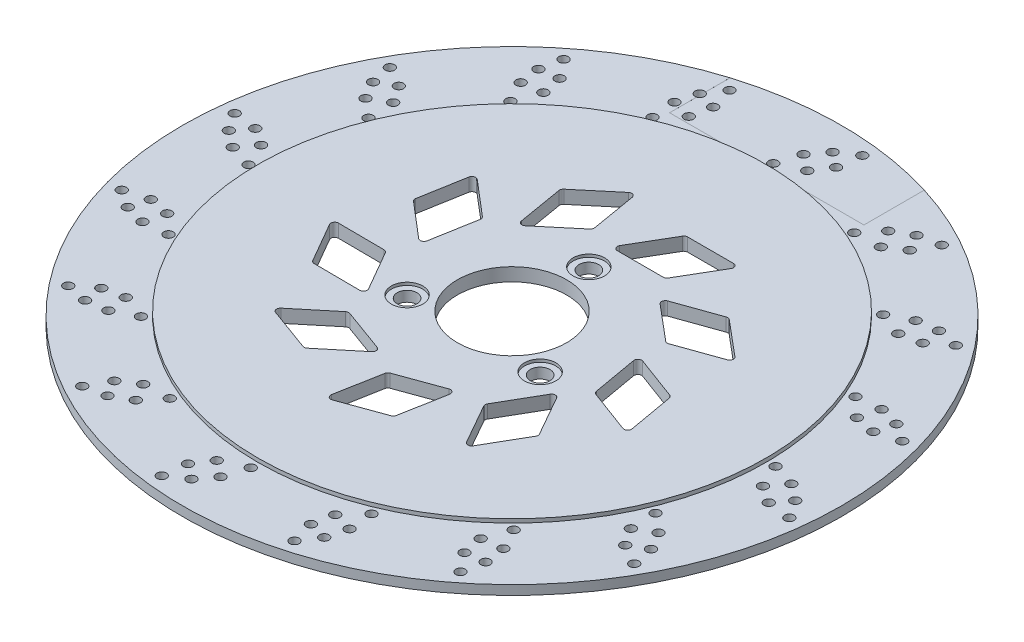
from build123d import *

# Parameters (mm, degrees)
SKETCH1_R           = 135
SKETCH1_R_2         = 29
BOSS_EXTRUDE1_DEPTH = 7
SKETCH1_3_R         = 175
SKETCH1_3_R_2       = 135
BOSS_EXTRUDE2_DEPTH = 5
SKETCH7_R           = 5.2
CUT_EXTRUDE9_DEPTH  = 248.586348574
SKETCH11_R          = 8.35
CUT_EXTRUDE10_DEPTH = 1.5
CIRPATTERN1_COUNT   = 3
CIRPATTERN2_COUNT   = 3
CUT_EXTRUDE11_DEPTH = 248.586348574
SKETCH14_R          = 2.5
CUT_EXTRUDE12_DEPTH = 248.53787589
CIRPATTERN3_COUNT   = 16
SKETCH15_R          = 175
SKETCH15_R_2        = 135
CUT_EXTRUDE13_DEPTH = 0.01
SKETCH16_W          = 103.216038505
SKETCH16_H          = 40.53333701
CUT_EXTRUDE14_DEPTH = 0.01
SKETCH17_W          = 102.14000893
SKETCH17_H          = 42.38101065
CUT_EXTRUDE15_DEPTH = 0.01


with BuildPart() as part:
    # Sketch1 → Boss-Extrude1 (new body)
    with BuildSketch(Plane(origin=(0, 0, 0), x_dir=(1, 0, 0), z_dir=(0, 1, 0))):
        Circle(SKETCH1_R)
        Circle(SKETCH1_R_2, mode=Mode.SUBTRACT)
    extrude(amount=BOSS_EXTRUDE1_DEPTH)

    # Sketch1_3 → Boss-Extrude2 (add)
    with BuildSketch(Plane(origin=(0, 0, 0), x_dir=(1, 0, 0), z_dir=(0, 1, 0))):
        Circle(SKETCH1_3_R)
        Circle(SKETCH1_3_R_2, mode=Mode.SUBTRACT)
    extrude(amount=BOSS_EXTRUDE2_DEPTH)

    # Sketch7 → Cut-Extrude9 (cut, through all)
    with BuildSketch(Plane(origin=(0, 7, 0), x_dir=(1, 0, 0), z_dir=(0, 1, 0))):
        with Locations((0, 40.8)):
            Circle(SKETCH7_R)
    cut_extrude9 = extrude(amount=-CUT_EXTRUDE9_DEPTH, mode=Mode.SUBTRACT)

    # Sketch11 → Cut-Extrude10 (cut)
    with BuildSketch(Plane(origin=(0, 7, 0), x_dir=(1, 0, 0), z_dir=(0, 1, 0))):
        with Locations((0, 40.8)):
            Circle(SKETCH11_R)
    cut_extrude10 = extrude(amount=-CUT_EXTRUDE10_DEPTH, mode=Mode.SUBTRACT)

    # CirPattern1: Cut-Extrude9 ×3 about axis
    cirpattern1_axis = Axis((0, 7, 0), (0, 1, 0))
    for i in range(1, CIRPATTERN1_COUNT):
        add(cut_extrude9.rotate(cirpattern1_axis, i * 360 / CIRPATTERN1_COUNT), mode=Mode.SUBTRACT)

    # CirPattern2: Cut-Extrude10 ×3 about axis
    cirpattern2_axis = Axis((0, 7, 0), (0, 1, 0))
    for i in range(1, CIRPATTERN2_COUNT):
        add(cut_extrude10.rotate(cirpattern2_axis, i * 360 / CIRPATTERN2_COUNT), mode=Mode.SUBTRACT)

    # Sketch13 → Cut-Extrude11 (cut, through all)
    with BuildSketch(Plane(origin=(0, 7, 0), x_dir=(1, 0, 0), z_dir=(0, 1, 0))):
        with BuildLine():
            Line((0.125749805, 55.8), (24.472230204, 55.8))
            ThreePointArc((24.472230204, 55.8), (25.466236439, 56.064502491), (26.197325549, 56.788048395))
            Line((26.197325549, 56.788048395), (38.516055508, 77.788048395))
            ThreePointArc((38.516055508, 77.788048395), (38.526457673, 79.794006235), (36.790960164, 80.8))
            Line((36.790960164, 80.8), (12.444479765, 80.8))
            ThreePointArc((12.444479765, 80.8), (11.45047353, 80.535497509), (10.71938442, 79.811951605))
            Line((10.71938442, 79.811951605), (-1.599345539, 58.811951605))
            ThreePointArc((-1.599345539, 58.811951605), (-1.609747704, 56.805993765), (0.125749805, 55.8))
        make_face()
        with BuildLine():
            Line((80.119731336, 38.247949908), (61.469245317, 53.897565848))
            ThreePointArc((61.469245317, 53.897565848), (60.537773441, 54.333880077), (59.512640348, 54.249546779))
            Line((59.512640348, 54.249546779), (36.577405913, 46.080940458))
            ThreePointArc((36.577405913, 46.080940458), (35.280032548, 44.550973984), (35.962860444, 42.664781755))
            Line((35.962860444, 42.664781755), (54.613346463, 27.015165815))
            ThreePointArc((54.613346463, 27.015165815), (55.544818339, 26.578851587), (56.569951431, 26.663184884))
            Line((56.569951431, 26.663184884), (79.505185866, 34.831791205))
            ThreePointArc((79.505185866, 34.831791205), (80.802559232, 36.361757679), (80.119731336, 38.247949908))
        make_face()
        with BuildLine():
            Line((85.959565155, -22.200008861), (81.731843201, 1.776593795))
            ThreePointArc((81.731843201, 1.776593795), (81.298751726, 2.709568466), (80.459245818, 3.303908262))
            Line((80.459245818, 3.303908262), (57.639157996, 11.788877302))
            ThreePointArc((57.639157996, 11.788877302), (55.661868846, 11.450790511), (54.972524367, 9.566970124))
            Line((54.972524367, 9.566970124), (59.200246321, -14.409632531))
            ThreePointArc((59.200246321, -14.409632531), (59.633337795, -15.342607202), (60.472843703, -15.936946998))
            Line((60.472843703, -15.936946998), (83.292931525, -24.421916038))
            ThreePointArc((83.292931525, -24.421916038), (85.270220675, -24.083829247), (85.959565155, -22.200008861))
        make_face()
        with BuildLine():
            Line((51.577938472, -72.259604595), (63.751178672, -51.174934076))
            ThreePointArc((63.751178672, -51.174934076), (64.019115913, -50.18184818), (63.758051334, -49.186933486))
            Line((63.758051334, -49.186933486), (51.730882834, -28.018600399))
            ThreePointArc((51.730882834, -28.018600399), (49.998873468, -27.006612941), (48.259908557, -28.006600989))
            Line((48.259908557, -28.006600989), (36.086668357, -49.091271507))
            ThreePointArc((36.086668357, -49.091271507), (35.818731116, -50.084357404), (36.079795695, -51.079272097))
            Line((36.079795695, -51.079272097), (48.106964195, -72.247605185))
            ThreePointArc((48.106964195, -72.247605185), (49.838973561, -73.259592643), (51.577938472, -72.259604595))
        make_face()
        with BuildLine():
            Line((-6.937603477, -88.507396099), (15.940604496, -80.180409384))
            ThreePointArc((15.940604496, -80.180409384), (16.78419964, -79.59188819), (17.223731408, -78.661930241))
            Line((17.223731408, -78.661930241), (21.617128039, -54.715131418))
            ThreePointArc((21.617128039, -54.715131418), (20.940824888, -52.826589888), (18.965920553, -52.474840078))
            Line((18.965920553, -52.474840078), (-3.91228742, -60.801826793))
            ThreePointArc((-3.91228742, -60.801826793), (-4.755882564, -61.390347987), (-5.195414332, -62.320305936))
            Line((-5.195414332, -62.320305936), (-9.588810962, -86.267104759))
            ThreePointArc((-9.588810962, -86.267104759), (-8.912507811, -88.155646288), (-6.937603477, -88.507396099))
        make_face()
        with BuildLine():
            Line((-62.206988287, -63.340861155), (-39.328780314, -71.667847871))
            ThreePointArc((-39.328780314, -71.667847871), (-38.30425481, -71.759266987), (-37.369788494, -71.329403442))
            Line((-37.369788494, -71.329403442), (-18.611545844, -55.809112192))
            ThreePointArc((-18.611545844, -55.809112192), (-17.915693019, -53.927686162), (-19.20245709, -52.388786137))
            Line((-19.20245709, -52.388786137), (-42.080665063, -44.061799422))
            ThreePointArc((-42.080665063, -44.061799422), (-43.105190567, -43.970380305), (-44.039656883, -44.40024385))
            Line((-44.039656883, -44.40024385), (-62.797899533, -59.9205351))
            ThreePointArc((-62.797899533, -59.9205351), (-63.493752358, -61.80196113), (-62.206988287, -63.340861155))
        make_face()
        with BuildLine():
            Line((-88.369056554, -8.535701158), (-76.195816355, -29.620371676))
            ThreePointArc((-76.195816355, -29.620371676), (-75.469747361, -30.348955082), (-74.477593672, -30.620323871))
            Line((-74.477593672, -30.620323871), (-50.131695213, -30.788656958))
            ThreePointArc((-50.131695213, -30.788656958), (-48.389283682, -29.794686577), (-48.38581628, -27.788704763))
            Line((-48.38581628, -27.788704763), (-60.55905648, -6.704034245))
            ThreePointArc((-60.55905648, -6.704034245), (-61.285125474, -5.975450839), (-62.277279162, -5.70408205))
            Line((-62.277279162, -5.70408205), (-86.623177622, -5.535748963))
            ThreePointArc((-86.623177622, -5.535748963), (-88.365589152, -6.529719344), (-88.369056554, -8.535701158))
        make_face()
        with BuildLine():
            Line((-73.182285778, 50.264140438), (-77.410007732, 26.287537783))
            ThreePointArc((-77.410007732, 26.287537783), (-77.322131, 25.262702361), (-76.736529675, 24.41707771))
            Line((-76.736529675, 24.41707771), (-58.19469187, 8.638885207))
            ThreePointArc((-58.19469187, 8.638885207), (-56.221015354, 8.280310152), (-54.928938915, 9.81475257))
            Line((-54.928938915, 9.81475257), (-50.701216961, 33.791355226))
            ThreePointArc((-50.701216961, 33.791355226), (-50.789093693, 34.816190648), (-51.374695018, 35.661815299))
            Line((-51.374695018, 35.661815299), (-69.916532823, 51.440007801))
            ThreePointArc((-69.916532823, 51.440007801), (-71.890209339, 51.798582857), (-73.182285778, 50.264140438))
        make_face()
        with BuildLine():
            Line((-23.752734786, 85.545564263), (-42.403220805, 69.895948324))
            ThreePointArc((-42.403220805, 69.895948324), (-42.994654834, 69.054392769), (-43.089615242, 68.030189428))
            Line((-43.089615242, 68.030189428), (-39.02777007, 44.024929137))
            ThreePointArc((-39.02777007, 44.024929137), (-37.746333745, 42.481589899), (-35.770225195, 42.826510261))
            Line((-35.770225195, 42.826510261), (-17.119739176, 58.4761262))
            ThreePointArc((-17.119739176, 58.4761262), (-16.528305147, 59.317681755), (-16.433344739, 60.341885096))
            Line((-16.433344739, 60.341885096), (-20.495189911, 84.347145387))
            ThreePointArc((-20.495189911, 84.347145387), (-21.776626235, 85.890484625), (-23.752734786, 85.545564263))
        make_face()
    extrude(amount=-CUT_EXTRUDE11_DEPTH, mode=Mode.SUBTRACT)

    # Sketch14 → Cut-Extrude12 (cut, through all)
    with BuildSketch(Plane(origin=(0, 5, 0), x_dir=(1, 0, 0), z_dir=(0, 1, 0))):
        with Locations((19.371769386, 166.652812155)):
            Circle(SKETCH14_R)
        with Locations((-0.614063154, 139.355520084)):
            Circle(SKETCH14_R)
        with Locations((9.923971718, 160.30436076)):
            Circle(SKETCH14_R)
        with Locations((3.241074211, 151.567148337)):
            Circle(SKETCH14_R)
        with Locations((17.867298021, 154.229530124)):
            Circle(SKETCH14_R)
        with Locations((11.764209377, 145.048000991)):
            Circle(SKETCH14_R)
    cut_extrude12 = extrude(amount=-CUT_EXTRUDE12_DEPTH, mode=Mode.SUBTRACT)

    # CirPattern3: Cut-Extrude12 ×16 about axis
    cirpattern3_axis = Axis((0, 5, 0), (0, 1, 0))
    for i in range(1, CIRPATTERN3_COUNT):
        add(cut_extrude12.rotate(cirpattern3_axis, i * 360 / CIRPATTERN3_COUNT), mode=Mode.SUBTRACT)

    # Sketch15 → Cut-Extrude13 (cut)
    with BuildSketch(Plane(origin=(0, 0, 0), x_dir=(1, 0, 0), z_dir=(0, 1, 0))):
        Circle(SKETCH15_R)
        Circle(SKETCH15_R_2, mode=Mode.SUBTRACT)
    extrude(amount=CUT_EXTRUDE13_DEPTH, mode=Mode.SUBTRACT)

    # Sketch16 → Cut-Extrude14 (cut)
    with BuildSketch(Plane(origin=(0, 5, 0), x_dir=(1, 0, 0), z_dir=(0, 1, 0))):
        with Locations((0.15788903, 155.384070993)):
            Rectangle(SKETCH16_W, SKETCH16_H)
    extrude(amount=-CUT_EXTRUDE14_DEPTH, mode=Mode.SUBTRACT)

    # Sketch17 → Cut-Extrude15 (cut)
    with BuildSketch(Plane(origin=(0, 0.01, 0), x_dir=(-1, 0, 0), z_dir=(0, -1, 0))):
        with Locations((-1.252363684, 156.456075718)):
            Rectangle(SKETCH17_W, SKETCH17_H)
    extrude(amount=-CUT_EXTRUDE15_DEPTH, mode=Mode.SUBTRACT)


solid = part.part
